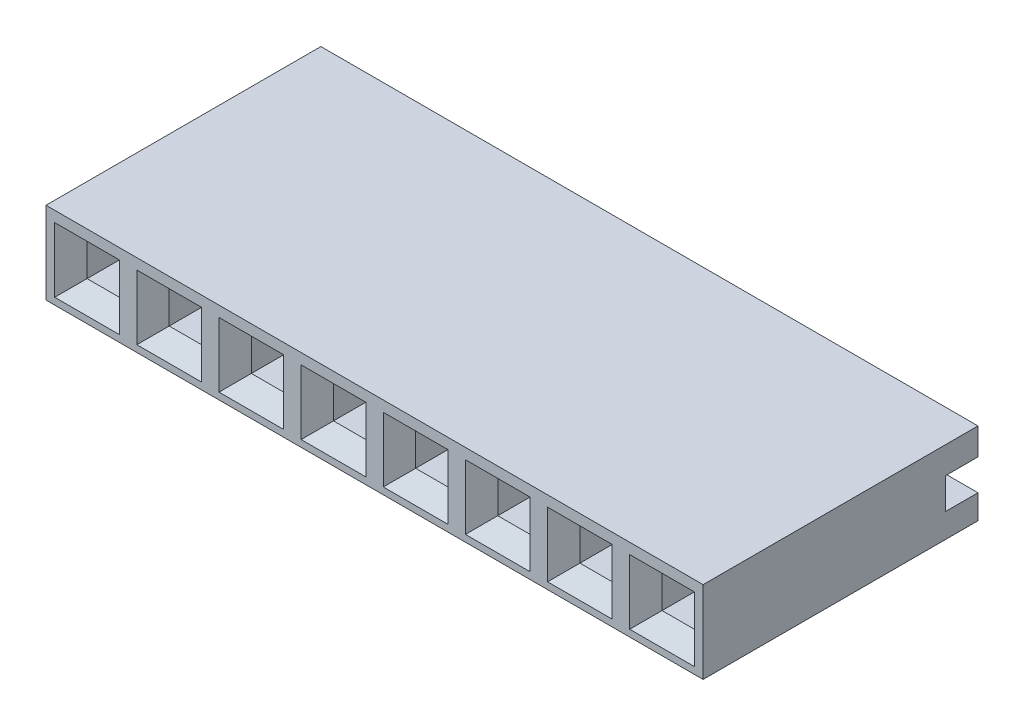
from build123d import *

# Parameters (mm, degrees)
BOSS_EXTRUDE1_DEPTH = 20.32
SKETCH2_W           = 2
SKETCH2_H           = 0.6
CUT_EXTRUDE1_DEPTH  = 5.5
SKETCH3_W           = 1
SKETCH3_H           = 1
CUT_EXTRUDE2_DEPTH  = 6
SKETCH4_W           = 2
SKETCH4_H           = 2
CUT_EXTRUDE3_DEPTH  = 0.5
CUT_EXTRUDE3_TAPER  = 45
LPATTERN1_COUNT     = 8
LPATTERN1_PITCH     = 2.54


with BuildPart() as part:
    # Sketch1 → Boss-Extrude1 (new body)
    with BuildSketch(Plane(origin=(0, 0, 0), x_dir=(0, 0, -1), z_dir=(1, 0, 0))):
        Polygon((8.5, 2.54), (0, 2.54), (0, 0), (8.5, 0), (8.5, 0.75), (7.5, 0.75), (7.5, 1.709993), (8.5, 1.709993), align=None)
    extrude(amount=-BOSS_EXTRUDE1_DEPTH)

    # Sketch2 → Cut-Extrude1 (cut)
    with BuildSketch(Plane(origin=(0, 0, -7.5), x_dir=(-1, 0, 0), z_dir=(0, 0, -1))):
        with Locations((1.27, 1.409993)):
            Rectangle(SKETCH2_W, SKETCH2_H)
    cut_extrude1 = extrude(amount=-CUT_EXTRUDE1_DEPTH, mode=Mode.SUBTRACT)

    # Sketch3 → Cut-Extrude2 (cut)
    with BuildSketch(Plane(origin=(0, 0, 0), x_dir=(-1, 0, 0), z_dir=(0, 0, -1))):
        with Locations((1.27, 1.209993)):
            Rectangle(SKETCH3_W, SKETCH3_H)
    cut_extrude2 = extrude(amount=CUT_EXTRUDE2_DEPTH, mode=Mode.SUBTRACT)

    # Sketch4 → Cut-Extrude3 (cut)
    with BuildSketch(Plane.XY):
        with Locations((-1.27, 1.209993)):
            Rectangle(SKETCH4_W, SKETCH4_H)
    cut_extrude3 = extrude(amount=-CUT_EXTRUDE3_DEPTH, taper=CUT_EXTRUDE3_TAPER, mode=Mode.SUBTRACT)

    # LPattern1: Cut-Extrude1, Cut-Extrude2, Cut-Extrude3 ×8
    with Locations(*[(-i * LPATTERN1_PITCH, 0, 0) for i in range(1, LPATTERN1_COUNT)]):
        add(cut_extrude1, mode=Mode.SUBTRACT)
        add(cut_extrude2, mode=Mode.SUBTRACT)
        add(cut_extrude3, mode=Mode.SUBTRACT)


solid = part.part
